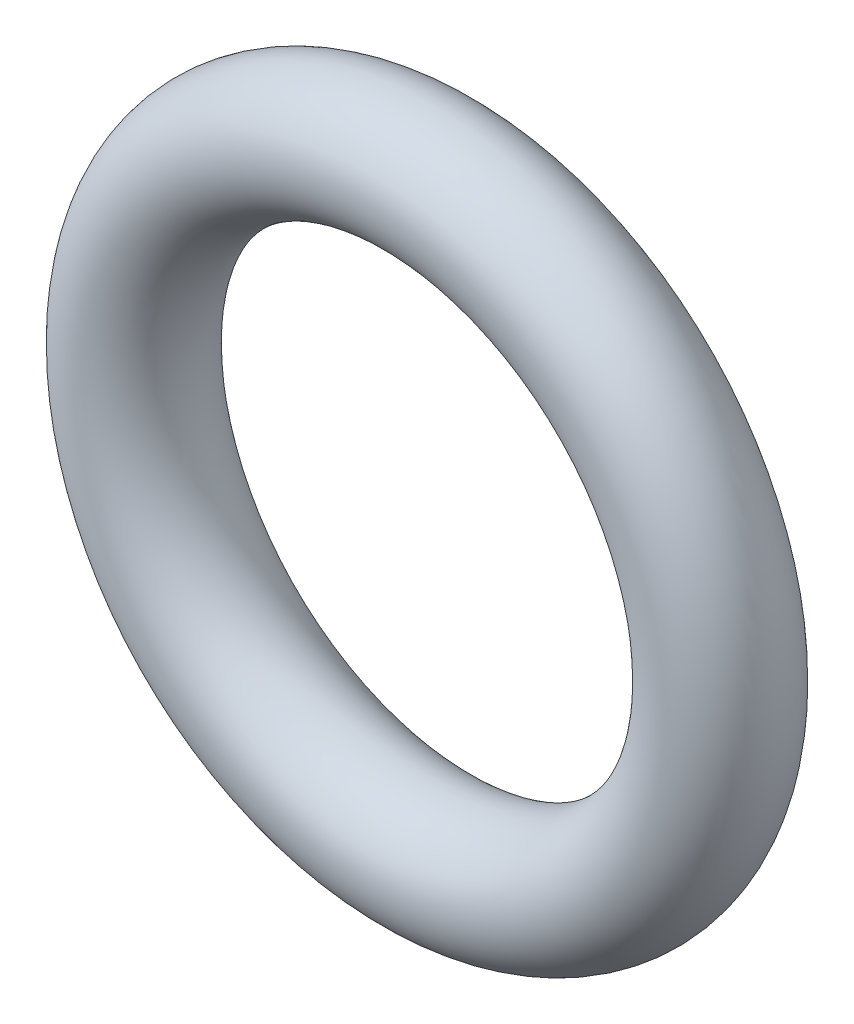
from build123d import *

# Parameters (mm, degrees)
SKETCH1_R = 0.8128


with BuildPart() as part:
    # Sketch1 → Revolve1 (revolve)
    with BuildSketch(Plane(origin=(0, 0, 0), x_dir=(0, -1, 0), z_dir=(1, 0, 0))):
        with Locations((3.8481, 0)):
            Circle(SKETCH1_R)
    revolve(axis=Axis((0, 0, 0.8128), (0, 0, -1)))


solid = part.part
